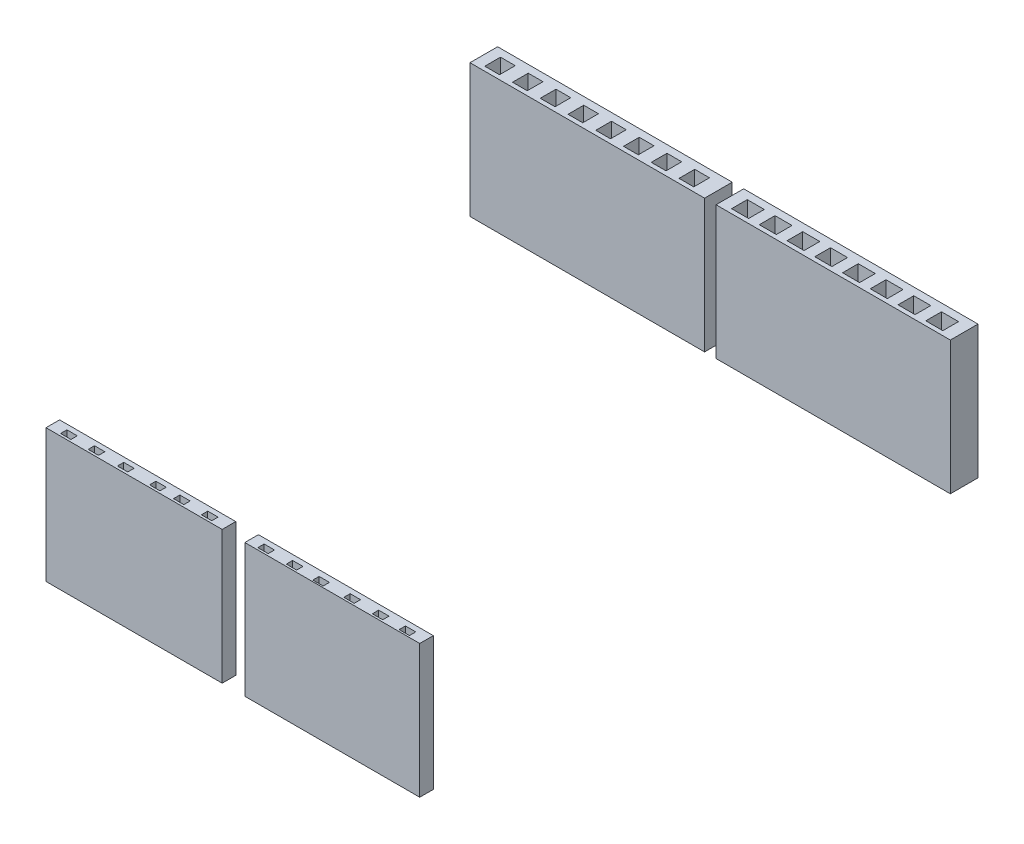
from build123d import *

# Parameters (mm, degrees)
CROQUIS1_W                = 21.13697434
CROQUIS1_H                = 2.491757137
CROQUIS1_W_2              = 1.3289884
CROQUIS1_H_2              = 1.414729588
SALIENTE_EXTRUIR1_DEPTH   = 12
CROQUIS1_W_3              = 21.11114987
CROQUIS1_W_4              = 1.534651331
SALIENTE_EXTRUIR1_2_DEPTH = 12
CROQUIS1_W_5              = 15.872405115
CROQUIS1_H_3              = 1.224219714
CROQUIS1_W_6              = 0.933395143
CROQUIS1_H_4              = 0.570408143
CROQUIS1_W_7              = 0.933395142
CROQUIS1_H_5              = 0.570408142
SALIENTE_EXTRUIR1_3_DEPTH = 12
CROQUIS1_W_8              = 15.758129679
SALIENTE_EXTRUIR1_4_DEPTH = 12


with BuildPart() as part:
    # Croquis1 → Saliente-Extruir1 (new body)
    with BuildSketch(Plane(origin=(0, 32.468175746, 0), x_dir=(1, 0, 0), z_dir=(0, 1, 0))):
        with Locations((18.292801832, -26.646426471)):
            Rectangle(CROQUIS1_W, CROQUIS1_H)
        with Locations((26.829996904, -26.792090507)):
            Rectangle(CROQUIS1_W_2, CROQUIS1_H_2, mode=Mode.SUBTRACT)
        with Locations((24.329996904, -26.792090507)):
            Rectangle(CROQUIS1_W_2, CROQUIS1_H_2, mode=Mode.SUBTRACT)
        with Locations((21.829996904, -26.792090507)):
            Rectangle(CROQUIS1_W_2, CROQUIS1_H_2, mode=Mode.SUBTRACT)
        with Locations((19.329996904, -26.792090507)):
            Rectangle(CROQUIS1_W_2, CROQUIS1_H_2, mode=Mode.SUBTRACT)
        with Locations((16.829996904, -26.792090507)):
            Rectangle(CROQUIS1_W_2, CROQUIS1_H_2, mode=Mode.SUBTRACT)
        with Locations((14.329996904, -26.792090507)):
            Rectangle(CROQUIS1_W_2, CROQUIS1_H_2, mode=Mode.SUBTRACT)
        with Locations((11.829996904, -26.792090507)):
            Rectangle(CROQUIS1_W_2, CROQUIS1_H_2, mode=Mode.SUBTRACT)
        with Locations((9.329996904, -26.792090507)):
            Rectangle(CROQUIS1_W_2, CROQUIS1_H_2, mode=Mode.SUBTRACT)
    extrude(amount=SALIENTE_EXTRUIR1_DEPTH)


with BuildPart() as body_2:
    # Croquis1 → Saliente-Extruir1 2 (new body)
    with BuildSketch(Plane(origin=(0, 32.468175746, 0), x_dir=(1, 0, 0), z_dir=(0, 1, 0))):
        with Locations((40.447935856, -26.646426471)):
            Rectangle(CROQUIS1_W_3, CROQUIS1_H)
        with Locations((49.165634111, -26.792090507)):
            Rectangle(CROQUIS1_W_4, CROQUIS1_H_2, mode=Mode.SUBTRACT)
        with Locations((46.665634111, -26.792090507)):
            Rectangle(CROQUIS1_W_4, CROQUIS1_H_2, mode=Mode.SUBTRACT)
        with Locations((44.165634111, -26.792090507)):
            Rectangle(CROQUIS1_W_4, CROQUIS1_H_2, mode=Mode.SUBTRACT)
        with Locations((41.665634111, -26.792090507)):
            Rectangle(CROQUIS1_W_4, CROQUIS1_H_2, mode=Mode.SUBTRACT)
        with Locations((39.165634111, -26.792090507)):
            Rectangle(CROQUIS1_W_4, CROQUIS1_H_2, mode=Mode.SUBTRACT)
        with Locations((36.665634111, -26.792090507)):
            Rectangle(CROQUIS1_W_4, CROQUIS1_H_2, mode=Mode.SUBTRACT)
        with Locations((34.165634111, -26.792090507)):
            Rectangle(CROQUIS1_W_4, CROQUIS1_H_2, mode=Mode.SUBTRACT)
        with Locations((31.665634112, -26.792090507)):
            Rectangle(CROQUIS1_W_4, CROQUIS1_H_2, mode=Mode.SUBTRACT)
    extrude(amount=SALIENTE_EXTRUIR1_2_DEPTH)


with BuildPart() as body_3:
    # Croquis1 → Saliente-Extruir1 3 (new body)
    with BuildSketch(Plane(origin=(0, 32.468175746, 0), x_dir=(1, 0, 0), z_dir=(0, 1, 0))):
        with Locations((25.040468248, -74.858584693)):
            Rectangle(CROQUIS1_W_5, CROQUIS1_H_3)
        with Locations((21.162525946, -74.978698992)):
            Rectangle(CROQUIS1_W_6, CROQUIS1_H_4, mode=Mode.SUBTRACT)
        with Locations((26.698030304, -74.978698992)):
            Rectangle(CROQUIS1_W_6, CROQUIS1_H_4, mode=Mode.SUBTRACT)
        with Locations((31.365006017, -74.978698992)):
            Rectangle(CROQUIS1_W_7, CROQUIS1_H_4, mode=Mode.SUBTRACT)
        with Locations((28.850024661, -74.978698992)):
            Rectangle(CROQUIS1_W_6, CROQUIS1_H_4, mode=Mode.SUBTRACT)
        with Locations((18.678299237, -74.978698992)):
            Rectangle(CROQUIS1_W_6, CROQUIS1_H_4, mode=Mode.SUBTRACT)
        with Locations((23.775536855, -74.956559737)):
            Rectangle(CROQUIS1_W_6, CROQUIS1_H_5, mode=Mode.SUBTRACT)
    extrude(amount=SALIENTE_EXTRUIR1_3_DEPTH)


with BuildPart() as body_4:
    # Croquis1 → Saliente-Extruir1 4 (new body)
    with BuildSketch(Plane(origin=(0, 32.468175746, 0), x_dir=(1, 0, 0), z_dir=(0, 1, 0))):
        with Locations((42.898049179, -74.858584693)):
            Rectangle(CROQUIS1_W_8, CROQUIS1_H_3)
        with Locations((46.791953516, -75.004626634)):
            Rectangle(CROQUIS1_W_7, CROQUIS1_H_5, mode=Mode.SUBTRACT)
        with Locations((41.476786731, -75.05648192)):
            Rectangle(CROQUIS1_W_6, CROQUIS1_H_4, mode=Mode.SUBTRACT)
        with Locations((36.47275166, -75.004626634)):
            Rectangle(CROQUIS1_W_6, CROQUIS1_H_5, mode=Mode.SUBTRACT)
        with Locations((39.039588303, -75.004626634)):
            Rectangle(CROQUIS1_W_6, CROQUIS1_H_5, mode=Mode.SUBTRACT)
        with Locations((44.225116873, -75.004626634)):
            Rectangle(CROQUIS1_W_6, CROQUIS1_H_5, mode=Mode.SUBTRACT)
        with Locations((49.229151945, -75.030554276)):
            Rectangle(CROQUIS1_W_6, CROQUIS1_H_4, mode=Mode.SUBTRACT)
    extrude(amount=SALIENTE_EXTRUIR1_4_DEPTH)


solid = Compound([part.part, body_2.part, body_3.part, body_4.part])
